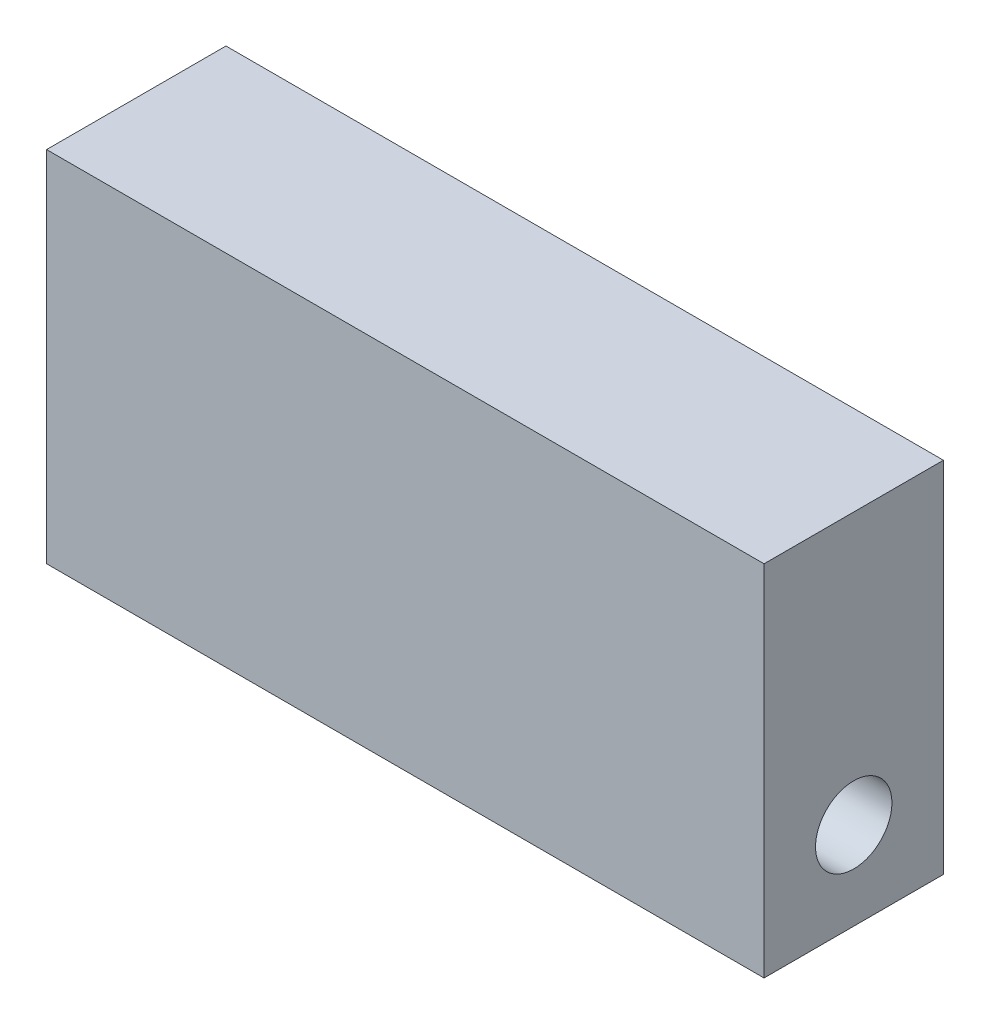
from build123d import *

# Parameters (mm, degrees)
SKETCH1_W                   = 50.8
SKETCH1_H                   = 12.7
BOSS_EXTRUDE1_DEPTH         = 25.4
F_1_4_28_TAPPED_HOLE1_D     = 5.4102
F_1_4_28_TAPPED_HOLE1_DEPTH = 29.972
F_1_4_28_TAPPED_HOLE1_TIP   = 1.625388061


with BuildPart() as part:
    # Sketch1 → Boss-Extrude1 (new body)
    with BuildSketch(Plane(origin=(0, 0, 0), x_dir=(1, 0, 0), z_dir=(0, 1, 0))):
        Rectangle(SKETCH1_W, SKETCH1_H)
    extrude(amount=BOSS_EXTRUDE1_DEPTH)

    # 1/4-28 Tapped Hole1
    with Locations(Plane(origin=(25.4, 0, 0), x_dir=(0, 0, -1), z_dir=(1, 0, 0))):
        with Locations((0, 6.215198177)):
            Hole(F_1_4_28_TAPPED_HOLE1_D / 2, depth=F_1_4_28_TAPPED_HOLE1_DEPTH)
            with Locations((0, 0, -(F_1_4_28_TAPPED_HOLE1_DEPTH + F_1_4_28_TAPPED_HOLE1_TIP / 2))):  # 118° drill point
                Cone(0, F_1_4_28_TAPPED_HOLE1_D / 2, F_1_4_28_TAPPED_HOLE1_TIP, mode=Mode.SUBTRACT)


solid = part.part
